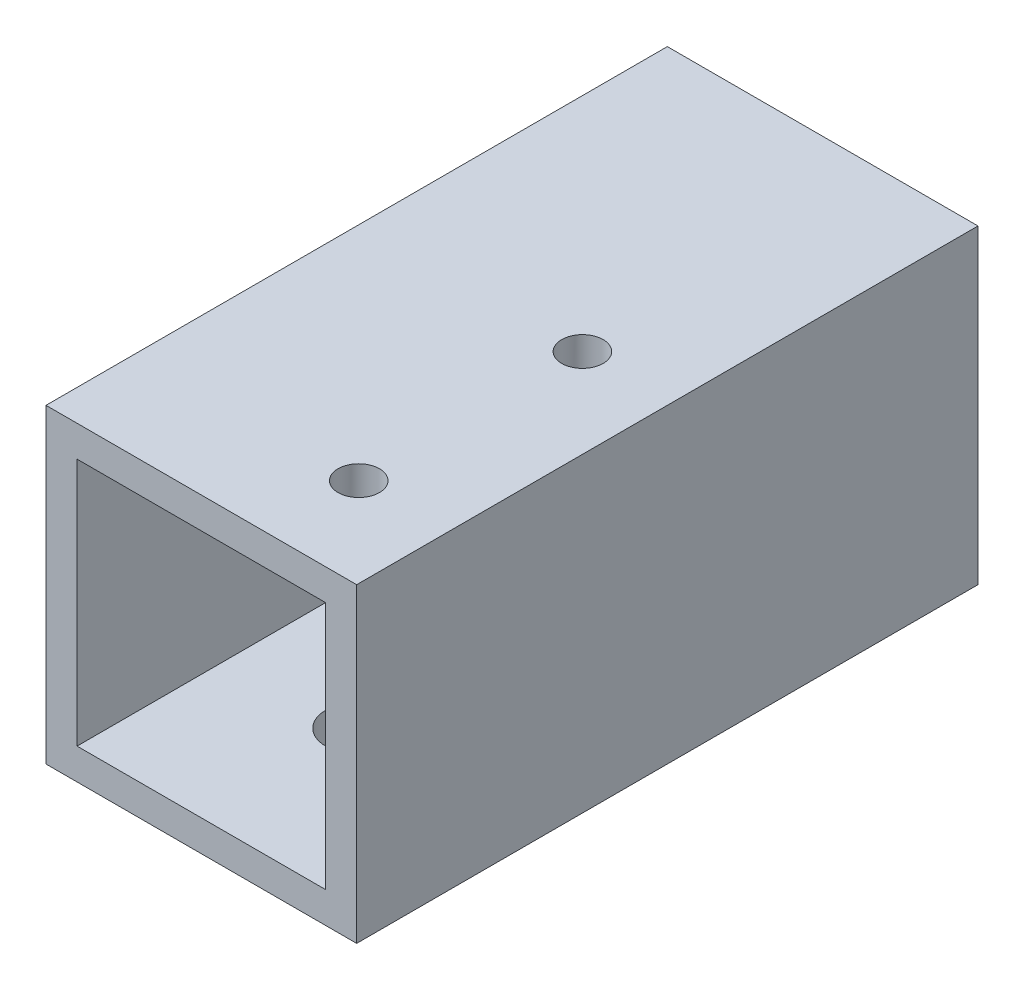
from build123d import *

# Parameters (mm, degrees)
SKETCH_1_W          = 15
SKETCH_1_H          = 15
SKETCH_1_W_2        = 12
SKETCH_1_H_2        = 12
EXTRUDE_2_DEPTH     = 30
SKETCH_2_R          = 1
CUT_EXTRUDE_1_DEPTH = 10
SKETCH_3_R          = 1.5
CUT_EXTRUDE_2_DEPTH = 10
SKETCH_5_R          = 1.5
CUT_EXTRUDE_4_DEPTH = 10


with BuildPart() as part:
    # ｽｹｯﾁ1 → ﾎﾞｽ - 押し出し2 (new body)
    with BuildSketch(Plane.XY):
        with Locations((0.489915859, 0.232626086)):
            Rectangle(SKETCH_1_W, SKETCH_1_H)
        with Locations((0.489915859, 0.232626086)):
            Rectangle(SKETCH_1_W_2, SKETCH_1_H_2, mode=Mode.SUBTRACT)
    extrude(amount=EXTRUDE_2_DEPTH)

    # ｽｹｯﾁ2 → ｶｯﾄ - 押し出し1 (cut)
    with BuildSketch(Plane(origin=(0, 7.732626086, 0), x_dir=(1, 0, 0), z_dir=(0, 1, 0))):
        with Locations((3.689915859, -25.6)):
            Circle(SKETCH_2_R)
        with Locations((3.689915859, -14.8)):
            Circle(SKETCH_2_R)
    extrude(amount=-CUT_EXTRUDE_1_DEPTH, mode=Mode.SUBTRACT)

    # ｽｹｯﾁ3 → ｶｯﾄ - 押し出し2 (cut)
    with BuildSketch(Plane.ZY.offset(7.010084141)):
        with Locations((7.5, 0.232626086)):
            Circle(SKETCH_3_R)
    extrude(amount=-CUT_EXTRUDE_2_DEPTH, mode=Mode.SUBTRACT)

    # ｽｹｯﾁ5 → ｶｯﾄ - 押し出し4 (cut)
    with BuildSketch(Plane.XZ.offset(7.267373914)):
        with Locations((0.489915859, 22.5)):
            Circle(SKETCH_5_R)
    extrude(amount=-CUT_EXTRUDE_4_DEPTH, mode=Mode.SUBTRACT)


solid = part.part
